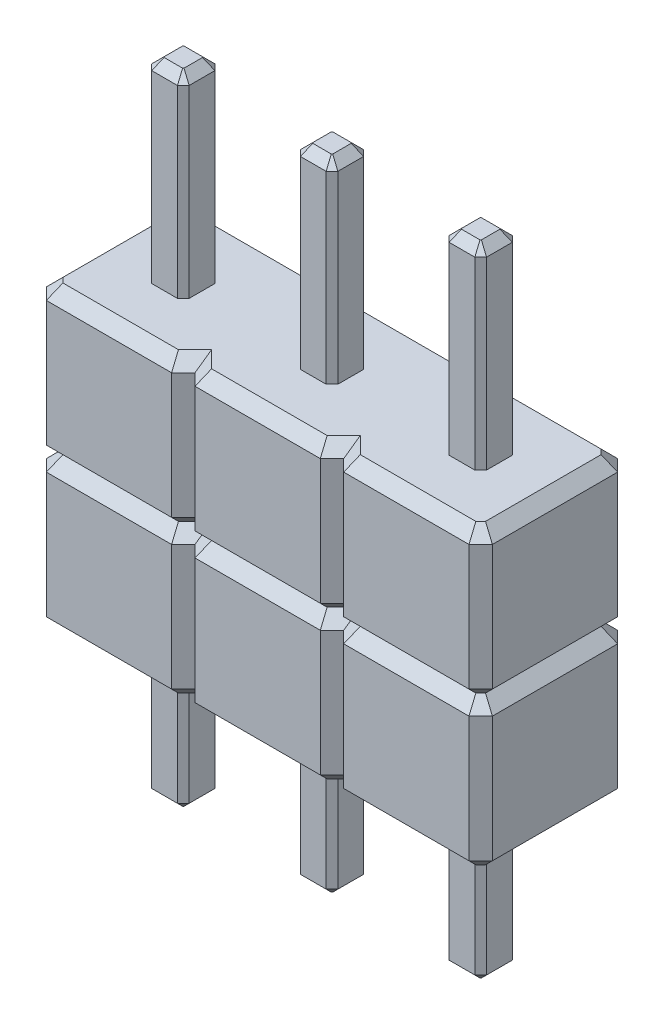
from build123d import *

# Parameters (mm, degrees)
EXTRUDE_1_DEPTH   = 2.54
EXTRUDE_1_2_DEPTH = 2.54
EXTRUDE_1_3_DEPTH = 2.54
EXTRUDE_2_DEPTH   = 8.38
EXTRUDE_3_DEPTH   = 2.54
EXTRUDE_START     = 5.08
EXTRUDE_4_DEPTH   = 2.54
CHAMFER_1_SIZE    = 0.15
CHAMFER_2_SIZE    = 0.2
CHAMFER_3_SIZE    = 0.2
CHAMFER_4_SIZE    = 0.2
CHAMFER_5_SIZE    = 0.2


with BuildPart() as part:
    # Эскиз1 → Бобышка-Вытянуть1 (new body)
    with BuildSketch(Plane(origin=(0, 0, 0), x_dir=(1, 0, 0), z_dir=(0, 1, 0))):
        Polygon((-1.59, -0.22), (-1.59, 0.22), (-1.49, 0.32), (-1.05, 0.32), (-0.95, 0.22), (-0.95, -0.22), (-1.05, -0.32), (-1.49, -0.32), align=None)
    extrude(amount=-EXTRUDE_1_DEPTH)



with BuildPart() as body_2:
    # Эскиз1 → Extrude 1 2 (new body)
    with BuildSketch(Plane(origin=(0, 0, 0), x_dir=(1, 0, 0), z_dir=(0, 1, 0))):
        Polygon((0.95, -0.22), (0.95, 0.22), (1.05, 0.32), (1.49, 0.32), (1.59, 0.22), (1.59, -0.22), (1.49, -0.32), (1.05, -0.32), align=None)
    extrude(amount=-EXTRUDE_1_2_DEPTH)


with BuildPart() as body_3:
    # Эскиз1 → Extrude 1 3 (new body)
    with BuildSketch(Plane(origin=(0, 0, 0), x_dir=(1, 0, 0), z_dir=(0, 1, 0))):
        Polygon((3.49, -0.22), (3.49, 0.22), (3.59, 0.32), (4.03, 0.32), (4.13, 0.22), (4.13, -0.22), (4.03, -0.32), (3.59, -0.32), align=None)
    extrude(amount=-EXTRUDE_1_3_DEPTH)


with BuildPart() as part_1:
    add(part.part)

    add(body_2.part)  # Бобышка-Вытянуть2 merges body 2

    add(body_3.part)  # Бобышка-Вытянуть2 merges body 3
    # Эскиз1<3> → Бобышка-Вытянуть2 (add)
    with BuildSketch(Plane(origin=(0, 0, 0), x_dir=(1, 0, 0), z_dir=(0, 1, 0))):
        Polygon((-1.59, -0.22), (-1.59, 0.22), (-1.49, 0.32), (-1.05, 0.32), (-0.95, 0.22), (-0.95, -0.22), (-1.05, -0.32), (-1.49, -0.32), align=None)
        Polygon((0.95, -0.22), (0.95, 0.22), (1.05, 0.32), (1.49, 0.32), (1.59, 0.22), (1.59, -0.22), (1.49, -0.32), (1.05, -0.32), align=None)
        Polygon((3.49, -0.22), (3.49, 0.22), (3.59, 0.32), (4.03, 0.32), (4.13, 0.22), (4.13, -0.22), (4.03, -0.32), (3.59, -0.32), align=None)
    extrude(amount=EXTRUDE_2_DEPTH)

    # Эскиз1<4> → Бобышка-Вытянуть3 (add)
    with BuildSketch(Plane(origin=(0, 0, 0), x_dir=(1, 0, 0), z_dir=(0, 1, 0))):
        Polygon((-2.54, 1.07), (-2.54, -1.07), (-2.34, -1.27), (-0.2, -1.27), (0, -1.07), (0, 1.07), (-0.2, 1.27), (-2.34, 1.27), align=None)
        Polygon((-1.59, -0.22), (-1.49, -0.32), (-1.05, -0.32), (-0.95, -0.22), (-0.95, 0.22), (-1.05, 0.32), (-1.49, 0.32), (-1.59, 0.22), align=None, mode=Mode.SUBTRACT)
        Polygon((0, 1.07), (0, -1.07), (0.2, -1.27), (2.34, -1.27), (2.54, -1.07), (2.54, 1.07), (2.34, 1.27), (0.2, 1.27), align=None)
        Polygon((0.95, -0.22), (1.05, -0.32), (1.49, -0.32), (1.59, -0.22), (1.59, 0.22), (1.49, 0.32), (1.05, 0.32), (0.95, 0.22), align=None, mode=Mode.SUBTRACT)
        Polygon((2.54, 1.07), (2.54, -1.07), (2.74, -1.27), (4.88, -1.27), (5.08, -1.07), (5.08, 1.07), (4.88, 1.27), (2.74, 1.27), align=None)
        Polygon((3.49, -0.22), (3.59, -0.32), (4.03, -0.32), (4.13, -0.22), (4.13, 0.22), (4.03, 0.32), (3.59, 0.32), (3.49, 0.22), align=None, mode=Mode.SUBTRACT)
    extrude(amount=EXTRUDE_3_DEPTH)

    # Фаска1
    chamfer_1_edges = [part_1.edges().sort_by_distance(p)[0] for p in [
        (-1.27, -2.54, 0.32),
        (1.59, -2.54, 0),
        (1.54, -2.54, 0.27),
        (1.27, -2.54, 0.32),
        (1, -2.54, 0.27),
        (0.95, 8.38, 0),
        (1, 8.38, -0.27),
        (1.27, 8.38, -0.32),
        (1.54, 8.38, -0.27),
        (0.95, -2.54, 0),
        (1, -2.54, -0.27),
        (1.27, -2.54, -0.32),
        (1.54, -2.54, -0.27),
        (1, 8.38, 0.27),
        (1.27, 8.38, 0.32),
        (1.54, 8.38, 0.27),
        (1.59, 8.38, 0),
        (-1, -2.54, 0.27),
        (4.13, -2.54, 0),
        (4.08, -2.54, 0.27),
        (3.81, -2.54, 0.32),
        (3.54, -2.54, 0.27),
        (3.49, 8.38, 0),
        (3.54, 8.38, -0.27),
        (3.81, 8.38, -0.32),
        (4.08, 8.38, -0.27),
        (3.49, -2.54, 0),
        (3.54, -2.54, -0.27),
        (3.81, -2.54, -0.32),
        (4.08, -2.54, -0.27),
        (3.54, 8.38, 0.27),
        (3.81, 8.38, 0.32),
        (4.08, 8.38, 0.27),
        (4.13, 8.38, 0),
        (-0.95, -2.54, 0),
        (-1, -2.54, -0.27),
        (-1.59, 8.38, 0),
        (-1, 8.38, -0.27),
        (-1.27, 8.38, -0.32),
        (-1.54, 8.38, -0.27),
        (-1.27, -2.54, -0.32),
        (-1.54, 8.38, 0.27),
        (-1.27, 8.38, 0.32),
        (-1, 8.38, 0.27),
        (-0.95, 8.38, 0),
        (-1.54, -2.54, -0.27),
        (-1.59, -2.54, 0),
        (-1.54, -2.54, 0.27),
    ]]
    chamfer(chamfer_1_edges, length=CHAMFER_1_SIZE)

    # Фаска2
    chamfer_2_edges = [part_1.edges().sort_by_distance(p)[0] for p in [
        (5.08, 2.54, 0),
        (4.98, 2.54, -1.17),
        (3.81, 2.54, -1.27),
        (2.64, 2.54, -1.17),
        (2.44, 2.54, -1.17),
        (1.27, 2.54, -1.27),
        (0.1, 2.54, -1.17),
        (-0.1, 2.54, -1.17),
        (-1.27, 2.54, -1.27),
        (-2.44, 2.54, -1.17),
        (-2.54, 2.54, 0),
        (-2.44, 2.54, 1.17),
        (-1.27, 2.54, 1.27),
        (-0.1, 2.54, 1.17),
        (0.1, 2.54, 1.17),
        (1.27, 2.54, 1.27),
        (2.44, 2.54, 1.17),
        (2.64, 2.54, 1.17),
        (3.81, 2.54, 1.27),
        (4.98, 2.54, 1.17),
    ]]
    chamfer(chamfer_2_edges, length=CHAMFER_2_SIZE)

    # Фаска4
    chamfer_4_edges = [part_1.edges().sort_by_distance(p)[0] for p in [
        (-2.54, 0, 0),
        (-2.44, 0, 1.17),
        (-1.27, 0, 1.27),
        (-0.1, 0, 1.17),
        (0.1, 0, 1.17),
        (1.27, 0, 1.27),
        (2.44, 0, 1.17),
        (2.64, 0, 1.17),
        (3.81, 0, 1.27),
        (4.98, 0, 1.17),
        (-2.44, 0, -1.17),
        (-1.27, 0, -1.27),
        (-0.1, 0, -1.17),
        (0.1, 0, -1.17),
        (1.27, 0, -1.27),
        (2.44, 0, -1.17),
        (2.64, 0, -1.17),
        (3.81, 0, -1.27),
        (4.98, 0, -1.17),
        (5.08, 0, 0),
    ]]
    chamfer(chamfer_4_edges, length=CHAMFER_4_SIZE)


with BuildPart() as body_2_2:
    # Эскиз1<5> → Бобышка-Вытянуть4 (new body)
    with BuildSketch(Plane(origin=(0, 0, 0), x_dir=(1, 0, 0), z_dir=(0, 1, 0)).offset(EXTRUDE_START)):
        Polygon((-2.54, 1.07), (-2.54, -1.07), (-2.34, -1.27), (-0.2, -1.27), (0, -1.07), (0, 1.07), (-0.2, 1.27), (-2.34, 1.27), align=None)
        Polygon((-1.59, -0.22), (-1.49, -0.32), (-1.05, -0.32), (-0.95, -0.22), (-0.95, 0.22), (-1.05, 0.32), (-1.49, 0.32), (-1.59, 0.22), align=None, mode=Mode.SUBTRACT)
        Polygon((0, 1.07), (0, -1.07), (0.2, -1.27), (2.34, -1.27), (2.54, -1.07), (2.54, 1.07), (2.34, 1.27), (0.2, 1.27), align=None)
        Polygon((0.95, -0.22), (1.05, -0.32), (1.49, -0.32), (1.59, -0.22), (1.59, 0.22), (1.49, 0.32), (1.05, 0.32), (0.95, 0.22), align=None, mode=Mode.SUBTRACT)
        Polygon((2.54, 1.07), (2.54, -1.07), (2.74, -1.27), (4.88, -1.27), (5.08, -1.07), (5.08, 1.07), (4.88, 1.27), (2.74, 1.27), align=None)
        Polygon((3.49, -0.22), (3.59, -0.32), (4.03, -0.32), (4.13, -0.22), (4.13, 0.22), (4.03, 0.32), (3.59, 0.32), (3.49, 0.22), align=None, mode=Mode.SUBTRACT)
    extrude(amount=-EXTRUDE_4_DEPTH)

    # Фаска3
    chamfer_3_edges = [body_2_2.edges().sort_by_distance(p)[0] for p in [
        (0.1, 2.54, -1.17),
        (-0.1, 2.54, -1.17),
        (-1.59, 2.54, 0),
        (-1.27, 2.54, -1.27),
        (-2.44, 2.54, -1.17),
        (1, 2.54, 0.27),
        (0.95, 2.54, 0),
        (1, 2.54, -0.27),
        (1.27, 2.54, -0.32),
        (1.54, 2.54, -0.27),
        (1.59, 2.54, 0),
        (1.54, 2.54, 0.27),
        (1.27, 2.54, 0.32),
        (-1.54, 2.54, -0.27),
        (3.54, 2.54, 0.27),
        (3.49, 2.54, 0),
        (3.54, 2.54, -0.27),
        (3.81, 2.54, -0.32),
        (4.08, 2.54, -0.27),
        (4.13, 2.54, 0),
        (4.08, 2.54, 0.27),
        (3.81, 2.54, 0.32),
        (-1.27, 2.54, -0.32),
        (-1, 2.54, -0.27),
        (-0.95, 2.54, 0),
        (-1, 2.54, 0.27),
        (-1.27, 2.54, 0.32),
        (-2.54, 2.54, 0),
        (-2.44, 2.54, 1.17),
        (-1.27, 2.54, 1.27),
        (-0.1, 2.54, 1.17),
        (0.1, 2.54, 1.17),
        (1.27, 2.54, 1.27),
        (2.44, 2.54, 1.17),
        (2.64, 2.54, 1.17),
        (-1.54, 2.54, 0.27),
        (3.81, 2.54, 1.27),
        (4.98, 2.54, 1.17),
        (5.08, 2.54, 0),
        (4.98, 2.54, -1.17),
        (3.81, 2.54, -1.27),
        (2.64, 2.54, -1.17),
        (2.44, 2.54, -1.17),
        (1.27, 2.54, -1.27),
    ]]
    chamfer(chamfer_3_edges, length=CHAMFER_3_SIZE)

    # Фаска5
    chamfer_5_edges = [body_2_2.edges().sort_by_distance(p)[0] for p in [
        (-2.44, 5.08, -1.17),
        (-1.27, 5.08, -1.27),
        (-0.1, 5.08, -1.17),
        (0.1, 5.08, -1.17),
        (1.27, 5.08, -1.27),
        (2.44, 5.08, -1.17),
        (2.64, 5.08, -1.17),
        (3.81, 5.08, -1.27),
        (4.98, 5.08, -1.17),
        (5.08, 5.08, 0),
        (4.98, 5.08, 1.17),
        (3.81, 5.08, 1.27),
        (2.64, 5.08, 1.17),
        (2.44, 5.08, 1.17),
        (1.27, 5.08, 1.27),
        (0.1, 5.08, 1.17),
        (-0.1, 5.08, 1.17),
        (-1.27, 5.08, 1.27),
        (-2.44, 5.08, 1.17),
        (-2.54, 5.08, 0),
    ]]
    chamfer(chamfer_5_edges, length=CHAMFER_5_SIZE)


solid = Compound([part_1.part, body_2_2.part])
